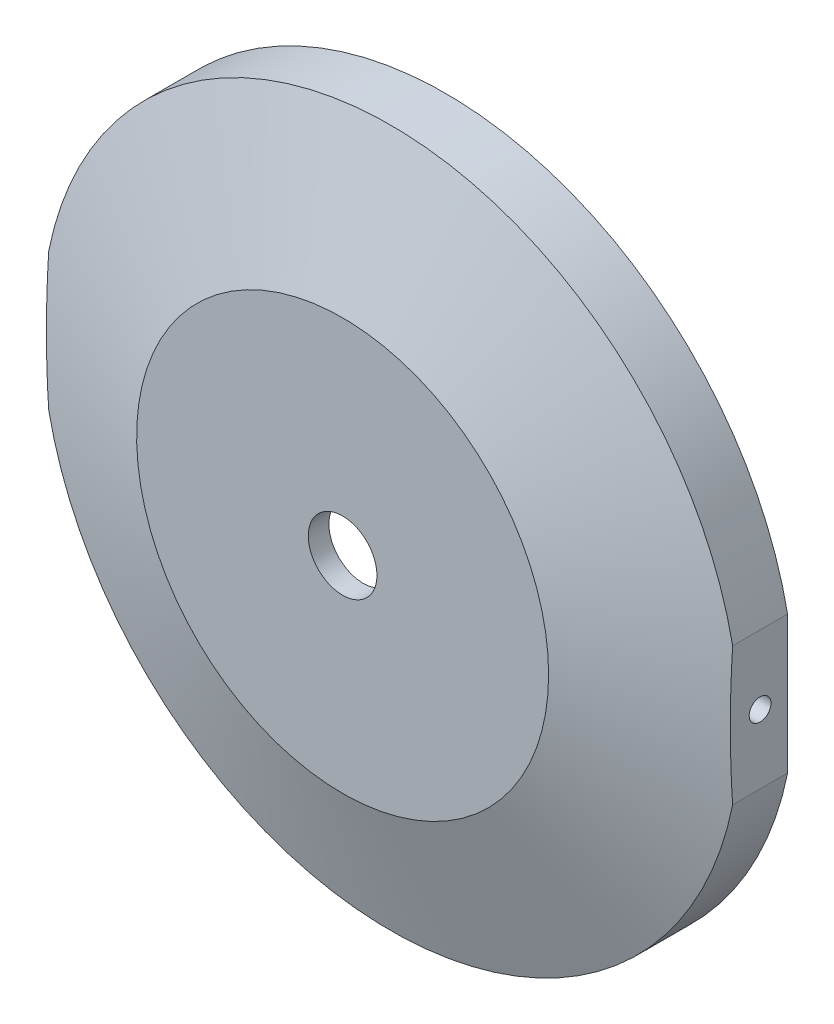
from build123d import *

# Parameters (mm, degrees)
SKETCH5_W                         = 25
SKETCH5_H                         = 25
CUT_EXTRUDE3_DEPTH                = 1
F_1_8_0_125_DIAMETER_HOLE2_REACH  = 115.234
F_1_8_0_125_DIAMETER_HOLE2_BORE_R = 1.5875


with BuildPart() as part:
    # Sketch2 → Revolve1 (revolve)
    with BuildSketch(Plane(origin=(0, 0, 0), x_dir=(0, 0, -1), z_dir=(1, 0, 0)), mode=Mode.PRIVATE) as revolve1_sk:
        Polygon((0, 30), (7, 50.8), (15, 50.8), (15, 40.8), (3, 30), (3, 5), (0, 5), align=None)
    revolve(revolve1_sk.sketch.rotate(Axis((0, 0, 1000), (0, 0, -1)), 90), axis=Axis((0, 0, 1000), (0, 0, -1)))

    # Sketch5 → Cut-Extrude3 (cut)
    with BuildSketch(Plane(origin=(50.8, 0, 0), x_dir=(0, 0, -1), z_dir=(1, 0, 0))):
        with Locations((10, 0)):
            Rectangle(SKETCH5_W, SKETCH5_H)
    cut_extrude3 = extrude(amount=-CUT_EXTRUDE3_DEPTH, mode=Mode.SUBTRACT)

    # 1/8 (0.125) Diameter Hole2 bore (on position points) → 1/8 (0.125) Diameter Hole2 (cut, up to next)
    with BuildSketch(Plane(origin=(49.8, 0, -11), x_dir=(0, 0, 1), z_dir=(1, 0, 0)), mode=Mode.PRIVATE) as f_1_8_0_125_diameter_hole2_sk1:
        Circle(F_1_8_0_125_DIAMETER_HOLE2_BORE_R)
    f_1_8_0_125_diameter_hole2_tool1 = extrude(f_1_8_0_125_diameter_hole2_sk1.sketch, amount=-F_1_8_0_125_DIAMETER_HOLE2_REACH, mode=Mode.PRIVATE) & part.part
    f_1_8_0_125_diameter_hole2 = f_1_8_0_125_diameter_hole2_tool1.solids().sort_by_distance((49.8, 0, -11))[0]
    add(f_1_8_0_125_diameter_hole2, mode=Mode.SUBTRACT)

    # Mirror2: Cut-Extrude3, 1/8 (0.125) Diameter Hole2 across plane
    add(cut_extrude3.mirror(Plane(origin=(0, 0, 0), x_dir=(0, 0, 1), z_dir=(1, 0, 0))), mode=Mode.SUBTRACT)
    add(f_1_8_0_125_diameter_hole2.mirror(Plane(origin=(0, 0, 0), x_dir=(0, 0, 1), z_dir=(1, 0, 0))), mode=Mode.SUBTRACT)


solid = part.part
